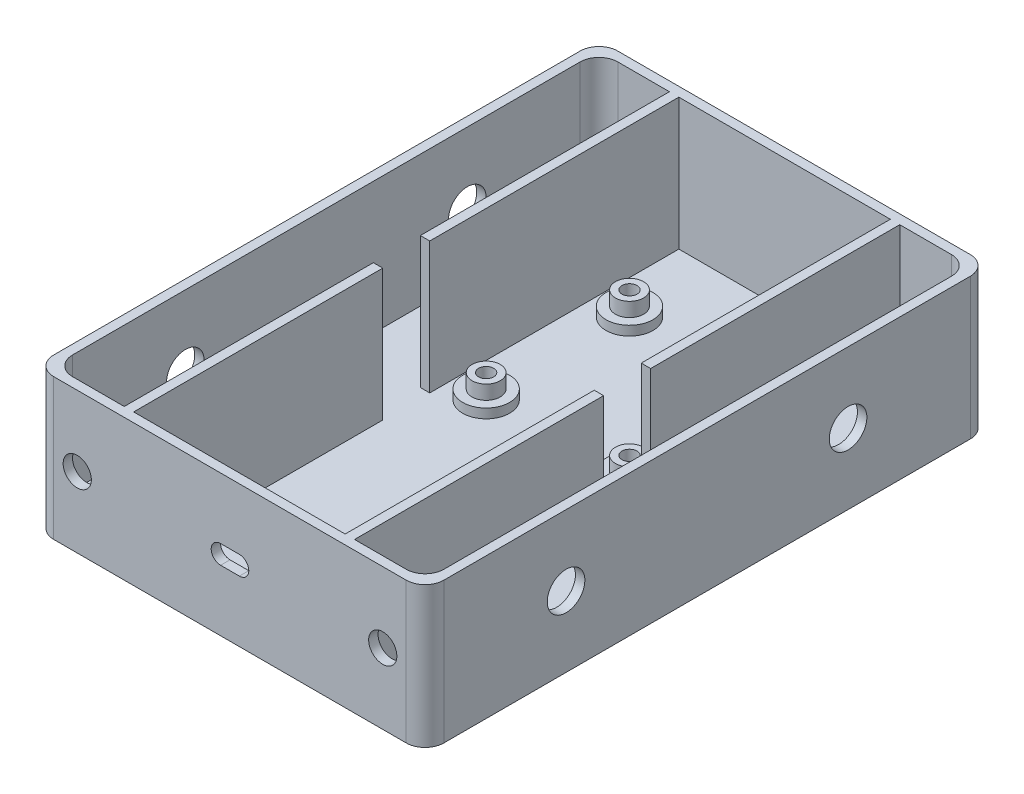
from build123d import *

# Parameters (mm, degrees)
SKETCH2_W                            = 83
SKETCH2_H                            = 30
BOSS_EXTRUDE1_DEPTH                  = 120
CUT_EXTRUDE1_DEPTH                   = 28
CUT_EXTRUDE4_REACH                   = 129.856
SKETCH10_R                           = 3
SKETCH10_R_2                         = 1.6
BOSS_EXTRUDE2_DEPTH                  = 5
SKETCH13_R                           = 5
BOSS_EXTRUDE_CC3D_SUPPORT_DEPTH      = 2
CUT_EXTRUDE_CC3D_ROUND_DEPTH         = 10
CUT_EXTRUDE_CC3D_ROUND_DEPTH_BACK    = 5
SKETCH10_3_R                         = 1.6
SKETCH14_R                           = 1.6
CUT_EXTRUDE_BOTTOM_HEX_CORNERS_DEPTH = 3.5
CUT_EXTRUDE_BOTTOM_HEX_CC3D_START    = -2.5
SKETCH14_5_R                         = 1.6
CUT_EXTRUDE_BOTTOM_HEX_CC3D_DEPTH    = 2.5
SKETCH14_4_R                         = 1.6
CUT_EXTRUDE_BOTTOM_ROUND_DEPTH       = 131.469345059
CUT_EXTRUDE12_DEPTH                  = 25
CUT_HOLES_RIGHT_REACH                = 148.677
SKETCH8_R                            = 4
CUT_HOLES_LEFT_REACH                 = 231.677
CUT_HOLES_LEFT_START                 = -83
SKETCH8_4_R                          = 4
FILLET1_4MM_R                        = 4
CUT_EXTRUDE14_REACH                  = 129.856
SKETCH15_R                           = 3
CUT_EXTRUDE15_REACH                  = 249.856
CUT_EXTRUDE15_START                  = -120
SKETCH15_2_R                         = 3


with BuildPart() as part:
    # Sketch2 → Boss-Extrude1 (new body)
    with BuildSketch(Plane.XY):
        Rectangle(SKETCH2_W, SKETCH2_H)
    extrude(amount=-BOSS_EXTRUDE1_DEPTH)

    # Sketch4 → Cut-Extrude1 (cut)
    with BuildSketch(Plane(origin=(0, 15, 0), x_dir=(1, 0, 0), z_dir=(0, 1, 0))):
        with BuildLine():
            Line((-24.5, 118), (-31, 118))
            ThreePointArc((-31, 118), (-33.48959236, 111.98959236), (-39.5, 109.5))
            Line((-39.5, 109.5), (-39.5, 10.5))
            ThreePointArc((-39.5, 10.5), (-33.48959236, 8.01040764), (-31, 2))
            Line((-31, 2), (-24.5, 2))
            Line((-24.5, 2), (-24.5, 55))
            Line((-24.5, 55), (-22.5, 55))
            Line((-22.5, 55), (-22.5, 2))
            Line((-22.5, 2), (22.5, 2))
            Line((22.5, 2), (22.5, 55))
            Line((22.5, 55), (24.5, 55))
            Line((24.5, 55), (24.5, 2))
            Line((24.5, 2), (31, 2))
            ThreePointArc((31, 2), (33.48959236, 8.01040764), (39.5, 10.5))
            Line((39.5, 10.5), (39.5, 109.5))
            ThreePointArc((39.5, 109.5), (33.48959236, 111.98959236), (31, 118))
            Line((31, 118), (24.5, 118))
            Line((24.5, 118), (24.5, 65))
            Line((24.5, 65), (22.5, 65))
            Line((22.5, 65), (22.5, 118))
            Line((22.5, 118), (-22.5, 118))
            Line((-22.5, 118), (-22.5, 65))
            Line((-22.5, 65), (-24.5, 65))
            Line((-24.5, 65), (-24.5, 118))
        make_face()
    extrude(amount=-CUT_EXTRUDE1_DEPTH, mode=Mode.SUBTRACT)

    # Sketch6 → Cut-Extrude4 (cut, up to next)
    with BuildSketch(Plane.XY, mode=Mode.PRIVATE) as cut_extrude4_sk1:
        with BuildLine():
            Line((-2, 2), (2, 2))
            ThreePointArc((2, 2), (4, 0), (2, -2))
            Line((2, -2), (-2, -2))
            ThreePointArc((-2, -2), (-4, 0), (-2, 2))
        make_face()
    cut_extrude4_tool1 = extrude(cut_extrude4_sk1.sketch, amount=-CUT_EXTRUDE4_REACH, mode=Mode.PRIVATE) & part.part
    add(cut_extrude4_tool1.solids().sort_by_distance((0, 0, 0))[0], mode=Mode.SUBTRACT)

    # Sketch10 → Boss-Extrude2 (add)
    # profile 1 of 4: a face of its own
    with BuildSketch(Plane(origin=(0, -13, 0), x_dir=(1, 0, 0), z_dir=(0, 1, 0))):
        with Locations((-15.25, 100.25)):
            Circle(SKETCH10_R)
        with Locations((-15.25, 100.25)):
            Circle(SKETCH10_R_2, mode=Mode.SUBTRACT)
    # profile 2 of 4: a face of its own
    with BuildSketch(Plane(origin=(0, -13, 0), x_dir=(1, 0, 0), z_dir=(0, 1, 0))):
        with Locations((15.25, 100.25)):
            Circle(SKETCH10_R)
        with Locations((15.25, 100.25)):
            Circle(SKETCH10_R_2, mode=Mode.SUBTRACT)
    # profile 3 of 4: a face of its own
    with BuildSketch(Plane(origin=(0, -13, 0), x_dir=(1, 0, 0), z_dir=(0, 1, 0))):
        with Locations((15.25, 69.75)):
            Circle(SKETCH10_R)
        with Locations((15.25, 69.75)):
            Circle(SKETCH10_R_2, mode=Mode.SUBTRACT)
    # profile 4 of 4: a face of its own
    with BuildSketch(Plane(origin=(0, -13, 0), x_dir=(1, 0, 0), z_dir=(0, 1, 0))):
        with Locations((-15.25, 69.75)):
            Circle(SKETCH10_R)
        with Locations((-15.25, 69.75)):
            Circle(SKETCH10_R_2, mode=Mode.SUBTRACT)
    extrude(amount=BOSS_EXTRUDE2_DEPTH)

    # Sketch13 → Boss-Extrude-cc3d-support (add)
    with BuildSketch(Plane(origin=(0, -13, 0), x_dir=(1, 0, 0), z_dir=(0, 1, 0))):
        with Locations((-15.25, 100.25)):
            Circle(SKETCH13_R)
        with Locations((15.25, 100.25)):
            Circle(SKETCH13_R)
        with Locations((-15.25, 69.75)):
            Circle(SKETCH13_R)
        with Locations((15.25, 69.75)):
            Circle(SKETCH13_R)
    extrude(amount=BOSS_EXTRUDE_CC3D_SUPPORT_DEPTH)

    # Sketch10_3 → Cut-Extrude-cc3d-round (cut, two sides: drawn at the far end of the back side and taken through both)
    with BuildSketch(Plane(origin=(0, -13, 0), x_dir=(1, 0, 0), z_dir=(0, 1, 0)).offset(-CUT_EXTRUDE_CC3D_ROUND_DEPTH_BACK)):
        with Locations((-15.25, 100.25)):
            Circle(SKETCH10_3_R)
        with Locations((15.25, 100.25)):
            Circle(SKETCH10_3_R)
        with Locations((-15.25, 69.75)):
            Circle(SKETCH10_3_R)
        with Locations((15.25, 69.75)):
            Circle(SKETCH10_3_R)
    extrude(amount=CUT_EXTRUDE_CC3D_ROUND_DEPTH + CUT_EXTRUDE_CC3D_ROUND_DEPTH_BACK, mode=Mode.SUBTRACT)

    # Sketch14 → Cut-Extrude-bottom-hex-corners (cut)
    # profile 1 of 4: a face of its own
    with BuildSketch(Plane.XZ.offset(15)):
        Polygon((-39.5, -6.936344802), (-36.65, -8.581793069), (-33.8, -6.936344802), (-33.8, -3.645448267), (-36.65, -2), (-39.5, -3.645448267), align=None)
        with Locations((-36.65, -5.290896534)):
            Circle(SKETCH14_R, mode=Mode.SUBTRACT)
    # profile 2 of 4: a face of its own
    with BuildSketch(Plane.XZ.offset(15)):
        Polygon((33.8, -116.354551733), (36.65, -118), (39.5, -116.354551733), (39.5, -113.063655198), (36.65, -111.418206931), (33.8, -113.063655198), align=None)
        with Locations((36.65, -114.709103466)):
            Circle(SKETCH14_R, mode=Mode.SUBTRACT)
    # profile 3 of 4: a face of its own
    with BuildSketch(Plane.XZ.offset(15)):
        Polygon((33.8, -6.936344802), (36.65, -8.581793069), (39.5, -6.936344802), (39.5, -3.645448267), (36.65, -2), (33.8, -3.645448267), align=None)
        with Locations((36.65, -5.290896534)):
            Circle(SKETCH14_R, mode=Mode.SUBTRACT)
    # profile 4 of 4: a face of its own
    with BuildSketch(Plane.XZ.offset(15)):
        Polygon((-39.5, -116.354551733), (-36.65, -118), (-33.8, -116.354551733), (-33.8, -113.063655198), (-36.65, -111.418206931), (-39.5, -113.063655198), align=None)
        with Locations((-36.65, -114.709103466)):
            Circle(SKETCH14_R, mode=Mode.SUBTRACT)
    extrude(amount=-CUT_EXTRUDE_BOTTOM_HEX_CORNERS_DEPTH, mode=Mode.SUBTRACT)

    # Sketch14_5 → Cut-Extrude-bottom-hex-cc3d (cut)
    # profile 1 of 4: a face of its own
    with BuildSketch(Plane.XZ.offset(15).offset(CUT_EXTRUDE_BOTTOM_HEX_CC3D_START)):
        Polygon((-18.1, -71.395448267), (-15.25, -73.040896534), (-12.4, -71.395448267), (-12.4, -68.104551733), (-15.25, -66.459103466), (-18.1, -68.104551733), align=None)
        with Locations((-15.25, -69.75)):
            Circle(SKETCH14_5_R, mode=Mode.SUBTRACT)
    # profile 2 of 4: a face of its own
    with BuildSketch(Plane.XZ.offset(15).offset(CUT_EXTRUDE_BOTTOM_HEX_CC3D_START)):
        Polygon((12.4, -71.395448267), (15.25, -73.040896534), (18.1, -71.395448267), (18.1, -68.104551733), (15.25, -66.459103466), (12.4, -68.104551733), align=None)
        with Locations((15.25, -69.75)):
            Circle(SKETCH14_5_R, mode=Mode.SUBTRACT)
    # profile 3 of 4: a face of its own
    with BuildSketch(Plane.XZ.offset(15).offset(CUT_EXTRUDE_BOTTOM_HEX_CC3D_START)):
        Polygon((12.4, -101.895448267), (15.25, -103.540896534), (18.1, -101.895448267), (18.1, -98.604551733), (15.25, -96.959103466), (12.4, -98.604551733), align=None)
        with Locations((15.25, -100.25)):
            Circle(SKETCH14_5_R, mode=Mode.SUBTRACT)
    # profile 4 of 4: a face of its own
    with BuildSketch(Plane.XZ.offset(15).offset(CUT_EXTRUDE_BOTTOM_HEX_CC3D_START)):
        Polygon((-18.1, -101.895448267), (-15.25, -103.540896534), (-12.4, -101.895448267), (-12.4, -98.604551733), (-15.25, -96.959103466), (-18.1, -98.604551733), align=None)
        with Locations((-15.25, -100.25)):
            Circle(SKETCH14_5_R, mode=Mode.SUBTRACT)
    extrude(amount=CUT_EXTRUDE_BOTTOM_HEX_CC3D_DEPTH, mode=Mode.SUBTRACT)

    # Sketch14_4 → Cut-Extrude-bottom-round (cut, through all)
    with BuildSketch(Plane.XZ.offset(15)):
        with Locations((-36.65, -5.290896534)):
            Circle(SKETCH14_4_R)
        with Locations((36.65, -5.290896534)):
            Circle(SKETCH14_4_R)
        with Locations((36.65, -114.709103466)):
            Circle(SKETCH14_4_R)
        with Locations((-36.65, -114.709103466)):
            Circle(SKETCH14_4_R)
    extrude(amount=-CUT_EXTRUDE_BOTTOM_ROUND_DEPTH, mode=Mode.SUBTRACT)

    # Sketch4_5 → Cut-Extrude12 (cut)
    with BuildSketch(Plane(origin=(0, 15, 0), x_dir=(1, 0, 0), z_dir=(0, 1, 0))):
        with BuildLine():
            Line((-31, 118), (-39.5, 118))
            Line((-39.5, 118), (-39.5, 109.5))
            ThreePointArc((-39.5, 109.5), (-33.48959236, 111.98959236), (-31, 118))
        make_face()
        with BuildLine():
            ThreePointArc((-31, 2), (-33.48959236, 8.01040764), (-39.5, 10.5))
            Line((-39.5, 10.5), (-39.5, 2))
            Line((-39.5, 2), (-31, 2))
        make_face()
        with BuildLine():
            Line((39.5, 118), (31, 118))
            ThreePointArc((31, 118), (33.48959236, 111.98959236), (39.5, 109.5))
            Line((39.5, 109.5), (39.5, 118))
        make_face()
        with BuildLine():
            Line((39.5, 2), (39.5, 10.5))
            ThreePointArc((39.5, 10.5), (33.48959236, 8.01040764), (31, 2))
            Line((31, 2), (39.5, 2))
        make_face()
    extrude(amount=-CUT_EXTRUDE12_DEPTH, mode=Mode.SUBTRACT)

    # Sketch8 → Cut-Holes-Right (cut, up to next)
    with BuildSketch(Plane(origin=(41.5, 0, 0), x_dir=(0, 0, -1), z_dir=(1, 0, 0)), mode=Mode.PRIVATE) as cut_holes_right_sk1:
        with Locations((30, 0)):
            Circle(SKETCH8_R)
    cut_holes_right_tool1 = extrude(cut_holes_right_sk1.sketch, amount=-CUT_HOLES_RIGHT_REACH, mode=Mode.PRIVATE) & part.part
    # Sketch8 → Cut-Holes-Right (cut, up to next)
    with BuildSketch(Plane(origin=(41.5, 0, 0), x_dir=(0, 0, -1), z_dir=(1, 0, 0)), mode=Mode.PRIVATE) as cut_holes_right_sk2:
        with Locations((90, 0)):
            Circle(SKETCH8_R)
    cut_holes_right_tool2 = extrude(cut_holes_right_sk2.sketch, amount=-CUT_HOLES_RIGHT_REACH, mode=Mode.PRIVATE) & part.part
    add(cut_holes_right_tool1.solids().sort_by_distance((41.5, 0, -30))[0], mode=Mode.SUBTRACT)
    add(cut_holes_right_tool2.solids().sort_by_distance((41.5, 0, -90))[0], mode=Mode.SUBTRACT)

    # Sketch8_4 → Cut-Holes-Left (cut, up to next)
    with BuildSketch(Plane(origin=(41.5, 0, 0), x_dir=(0, 0, -1), z_dir=(1, 0, 0)).offset(CUT_HOLES_LEFT_START), mode=Mode.PRIVATE) as cut_holes_left_sk1:
        with Locations((30, 0)):
            Circle(SKETCH8_4_R)
    cut_holes_left_tool1 = extrude(cut_holes_left_sk1.sketch, amount=CUT_HOLES_LEFT_REACH, mode=Mode.PRIVATE) & part.part
    # Sketch8_4 → Cut-Holes-Left (cut, up to next)
    with BuildSketch(Plane(origin=(41.5, 0, 0), x_dir=(0, 0, -1), z_dir=(1, 0, 0)).offset(CUT_HOLES_LEFT_START), mode=Mode.PRIVATE) as cut_holes_left_sk2:
        with Locations((90, 0)):
            Circle(SKETCH8_4_R)
    cut_holes_left_tool2 = extrude(cut_holes_left_sk2.sketch, amount=CUT_HOLES_LEFT_REACH, mode=Mode.PRIVATE) & part.part
    add(cut_holes_left_tool1.solids().sort_by_distance((-41.5, 0, -30))[0], mode=Mode.SUBTRACT)
    add(cut_holes_left_tool2.solids().sort_by_distance((-41.5, 0, -90))[0], mode=Mode.SUBTRACT)

    # Fillet1_4mm
    fillet1_4mm_edges = [part.edges().sort_by_distance(p)[0] for p in [
        (41.5, 0, -120),
        (-39.5, 2.5, -118),
        (39.5, 2.5, -118),
        (39.5, 2.5, -2),
        (-41.5, 0, -120),
        (-39.5, 2.5, -2),
        (41.5, 0, 0),
        (-41.5, 0, 0),
    ]]
    fillet(fillet1_4mm_edges, radius=FILLET1_4MM_R)

    # Sketch15 → Cut-Extrude14 (cut, up to next)
    with BuildSketch(Plane.XY, mode=Mode.PRIVATE) as cut_extrude14_sk1:
        with Locations((-32.5, 0)):
            Circle(SKETCH15_R)
    cut_extrude14_tool1 = extrude(cut_extrude14_sk1.sketch, amount=-CUT_EXTRUDE14_REACH, mode=Mode.PRIVATE) & part.part
    # Sketch15 → Cut-Extrude14 (cut, up to next)
    with BuildSketch(Plane.XY, mode=Mode.PRIVATE) as cut_extrude14_sk2:
        with Locations((32.5, 0)):
            Circle(SKETCH15_R)
    cut_extrude14_tool2 = extrude(cut_extrude14_sk2.sketch, amount=-CUT_EXTRUDE14_REACH, mode=Mode.PRIVATE) & part.part
    add(cut_extrude14_tool1.solids().sort_by_distance((-32.5, 0, 0))[0], mode=Mode.SUBTRACT)
    add(cut_extrude14_tool2.solids().sort_by_distance((32.5, 0, 0))[0], mode=Mode.SUBTRACT)

    # Sketch15_2 → Cut-Extrude15 (cut, up to next)
    with BuildSketch(Plane.XY.offset(CUT_EXTRUDE15_START), mode=Mode.PRIVATE) as cut_extrude15_sk1:
        with Locations((-32.5, 0)):
            Circle(SKETCH15_2_R)
    cut_extrude15_tool1 = extrude(cut_extrude15_sk1.sketch, amount=CUT_EXTRUDE15_REACH, mode=Mode.PRIVATE) & part.part
    # Sketch15_2 → Cut-Extrude15 (cut, up to next)
    with BuildSketch(Plane.XY.offset(CUT_EXTRUDE15_START), mode=Mode.PRIVATE) as cut_extrude15_sk2:
        with Locations((32.5, 0)):
            Circle(SKETCH15_2_R)
    cut_extrude15_tool2 = extrude(cut_extrude15_sk2.sketch, amount=CUT_EXTRUDE15_REACH, mode=Mode.PRIVATE) & part.part
    add(cut_extrude15_tool1.solids().sort_by_distance((-32.5, 0, -120))[0], mode=Mode.SUBTRACT)
    add(cut_extrude15_tool2.solids().sort_by_distance((32.5, 0, -120))[0], mode=Mode.SUBTRACT)


solid = part.part
